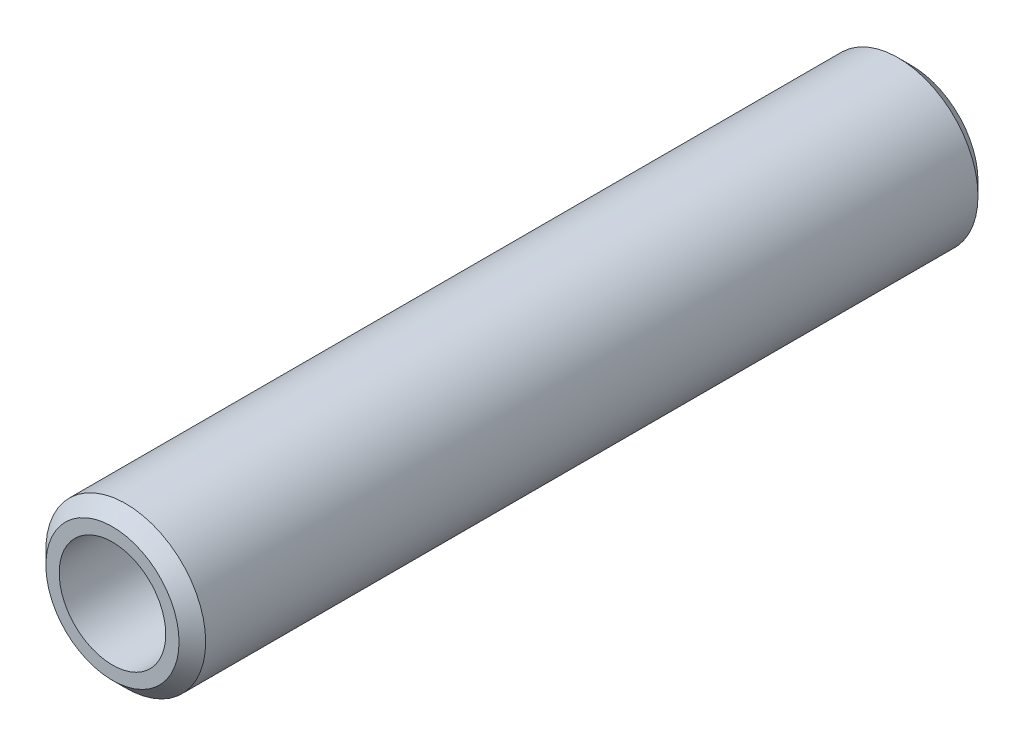
from build123d import *

# Parameters (mm, degrees)
IZIM1_R                     = 3
IZIM1_R_2                   = 2
Y_KSEKLIK_EKSTR_ZYON1_DEPTH = 30
PAH1_SIZE                   = 0.5


with BuildPart() as part:
    # Çizim1 → Yükseklik-Ekstrüzyon1 (new body)
    with BuildSketch(Plane.XY):
        with Locations((-22.834449066, 8.614006791)):
            Circle(IZIM1_R)
        with Locations((-22.834449066, 8.614006791)):
            Circle(IZIM1_R_2, mode=Mode.SUBTRACT)
    extrude(amount=Y_KSEKLIK_EKSTR_ZYON1_DEPTH)

    # Pah1
    pah1_edges = [part.edges().sort_by_distance(p)[0] for p in [
        (-25.834449066, 8.614006791, 0),
        (-25.834449066, 8.614006791, 30),
    ]]
    chamfer(pah1_edges, length=PAH1_SIZE)


solid = part.part
